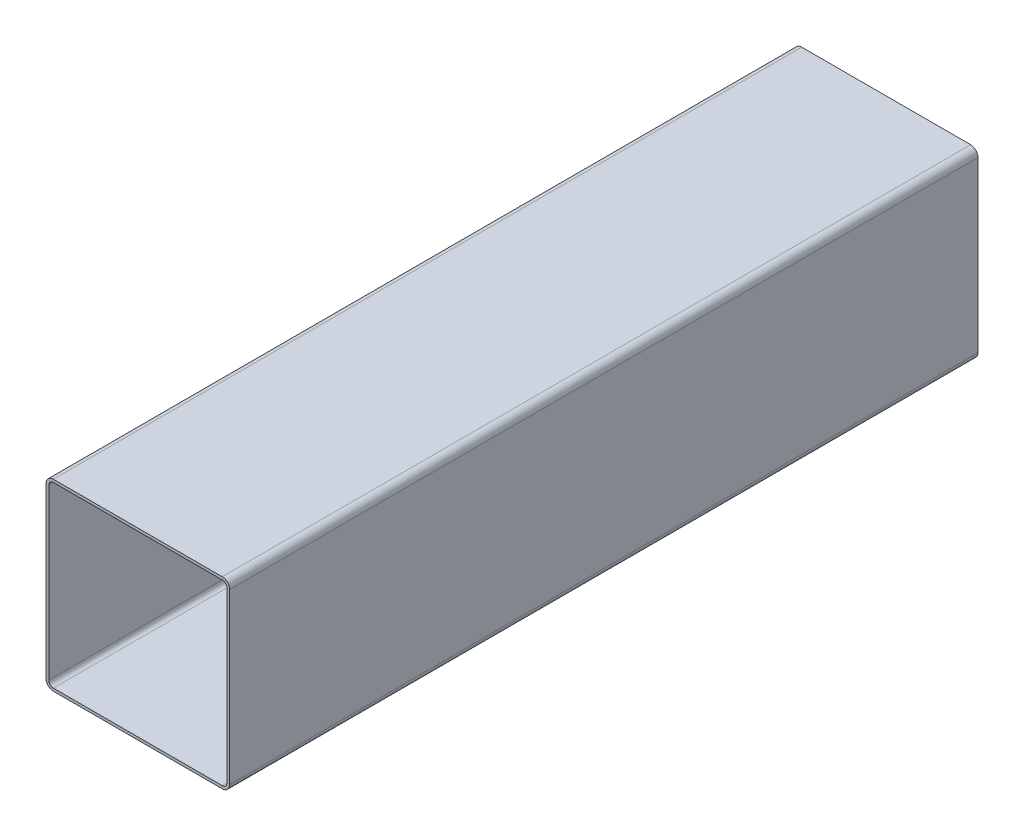
from build123d import *

# Parameters (mm, degrees)
EXTRUDE_1_DEPTH = 815


with BuildPart() as part:
    # Эскиз1 → Вытянуть-Тонкостенный1 (new body)
    with BuildSketch(Plane.XY):
        with BuildLine():
            Line((-92, 100), (92, 100))
            ThreePointArc((92, 100), (97.656854249, 97.656854249), (100, 92))
            Line((100, 92), (100, -92))
            ThreePointArc((100, -92), (97.656854249, -97.656854249), (92, -100))
            Line((92, -100), (-92, -100))
            ThreePointArc((-92, -100), (-97.656854249, -97.656854249), (-100, -92))
            Line((-100, -92), (-100, 92))
            ThreePointArc((-100, 92), (-97.656854249, 97.656854249), (-92, 100))
        make_face()
        with BuildLine():
            Line((-92, 97), (92, 97))
            ThreePointArc((92, 97), (95.535533906, 95.535533906), (97, 92))
            Line((97, 92), (97, -92))
            ThreePointArc((97, -92), (95.535533906, -95.535533906), (92, -97))
            Line((92, -97), (-92, -97))
            ThreePointArc((-92, -97), (-95.535533906, -95.535533906), (-97, -92))
            Line((-97, -92), (-97, 92))
            ThreePointArc((-97, 92), (-95.535533906, 95.535533906), (-92, 97))
        make_face(mode=Mode.SUBTRACT)
    extrude(amount=EXTRUDE_1_DEPTH)


solid = part.part
